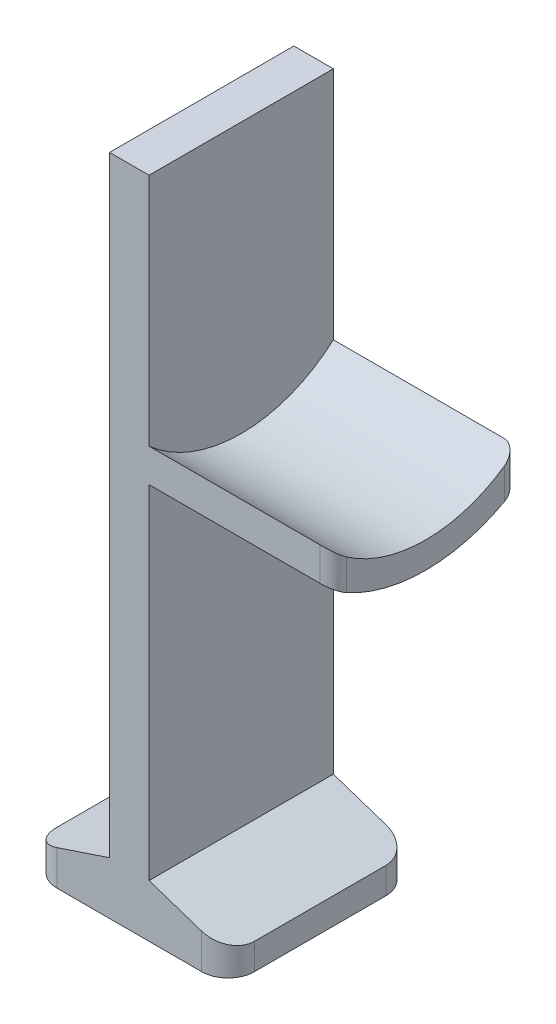
from build123d import *

# Parameters (mm, degrees)
ESBO_O1_W                = 3
ESBO_O1_H                = 50.4
RESSALTO_EXTRUS_O1_DEPTH = 7
FILETE1_R                = 2
RESSALTO_EXTRUS_O2_DEPTH = 14
FILETE2_R                = 1


with BuildPart() as part:
    # Esboço1 → Ressalto-extrusão1 (new body, symmetric)
    with BuildSketch(Plane.XY):
        with Locations((0, 25.2)):
            Rectangle(ESBO_O1_W, ESBO_O1_H)
        Polygon((-7.5, 0), (-1.5, 0), (-1.5, 4), (-7.5, 2), align=None)
        Polygon((1.5, 4), (1.5, 0), (7.5, 0), (7.5, 2), align=None)
    extrude(amount=RESSALTO_EXTRUS_O1_DEPTH, both=True)

    # Filete1
    filete1_edges = [part.edges().sort_by_distance(p)[0] for p in [
        (-7.5, 1, -7),
        (7.5, 1, -7),
        (7.5, 1, 7),
        (-7.5, 1, 7),
    ]]
    fillet(filete1_edges, radius=FILETE1_R)

    # Esboço3 → Ressalto-extrusão2 (add)
    with BuildSketch(Plane(origin=(1.5, 0, 0), x_dir=(0, 0, -1), z_dir=(1, 0, 0))):
        with BuildLine():
            Line((-7, 32.573762079), (-7, 30.043842411))
            ThreePointArc((-7, 30.043842411), (0, 27.9), (7, 30.043842411))
            Line((7, 30.043842411), (7, 32.573762079))
            ThreePointArc((7, 32.573762079), (0, 29.9), (-7, 32.573762079))
        make_face()
    extrude(amount=RESSALTO_EXTRUS_O2_DEPTH)

    # Filete2
    filete2_edges = [part.edges().sort_by_distance(p)[0] for p in [
        (15.5, 31.308802245, 7),
        (15.5, 31.308802245, -7),
    ]]
    fillet(filete2_edges, radius=FILETE2_R)


solid = part.part
